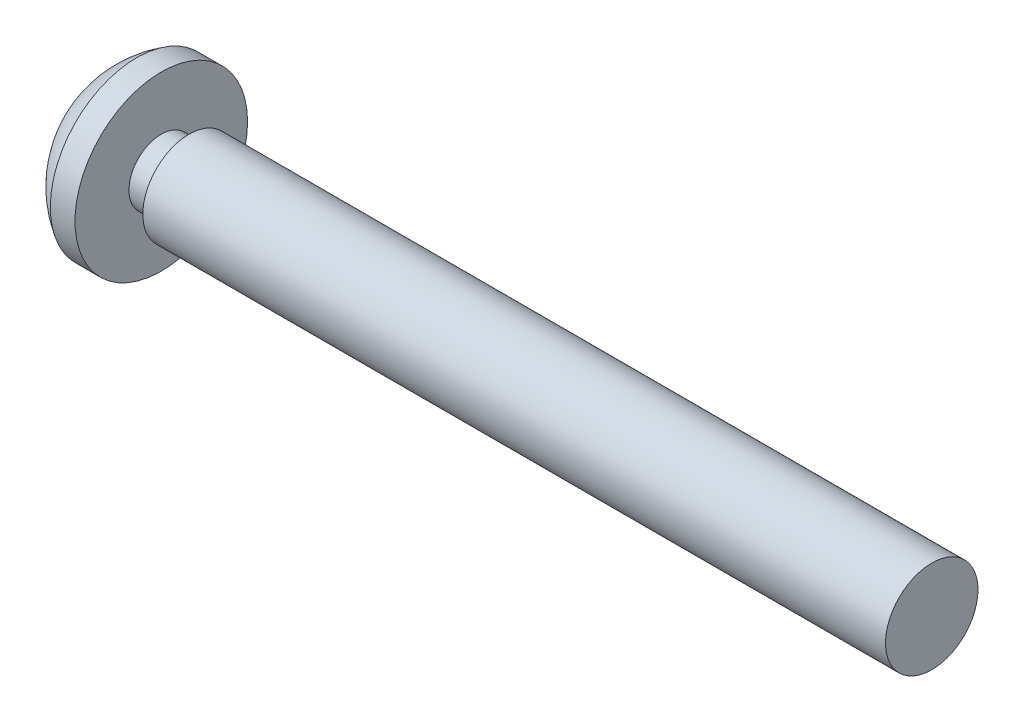
from build123d import *

# Parameters (mm, degrees)
CUT_EXTRUDE_5_DEPTH = 1.2


with BuildPart() as part:
    # 草图2 → 旋转1 (revolve)
    with BuildSketch(Plane.XY):
        with BuildLine():
            Line((0, 0), (0, 1.5))
            Line((0, 1.5), (-24.1, 1.5))
            Line((-24.1, 1.5), (-24.1, 1.05))
            Line((-24.1, 1.05), (-25, 1.05))
            Line((-25, 1.05), (-25, 2.8))
            Line((-25, 2.8), (-25.8, 2.8))
            ThreePointArc((-25.8, 2.8), (-26.971790212, 1.61245155), (-27.4, 0))
            Line((-27.4, 0), (0, 0))
        make_face()
    revolve(axis=Axis((0, 0, 0), (-1, 0, 0)))

    # 草图3 → 切除-拉伸5 (cut)
    with BuildSketch(Plane(origin=(-27.4, 0, 0), x_dir=(0, 0, -1), z_dir=(1, 0, 0))):
        with BuildLine():
            Line((0.375, 1.8), (-0.375, 1.8))
            Line((-0.375, 1.8), (-0.375, 0.675))
            ThreePointArc((-0.375, 0.675), (-0.462867966, 0.462867966), (-0.675, 0.375))
            Line((-0.675, 0.375), (-1.8, 0.375))
            Line((-1.8, 0.375), (-1.8, -0.375))
            Line((-1.8, -0.375), (-0.675, -0.375))
            ThreePointArc((-0.675, -0.375), (-0.462867966, -0.462867966), (-0.375, -0.675))
            Line((-0.375, -0.675), (-0.375, -1.8))
            Line((-0.375, -1.8), (0.375, -1.8))
            Line((0.375, -1.8), (0.375, -0.675))
            ThreePointArc((0.375, -0.675), (0.462867966, -0.462867966), (0.675, -0.375))
            Line((0.675, -0.375), (1.8, -0.375))
            Line((1.8, -0.375), (1.8, 0.375))
            Line((1.8, 0.375), (0.675, 0.375))
            ThreePointArc((0.675, 0.375), (0.462867966, 0.462867966), (0.375, 0.675))
            Line((0.375, 0.675), (0.375, 1.8))
        make_face()
    extrude(amount=CUT_EXTRUDE_5_DEPTH, mode=Mode.SUBTRACT)


solid = part.part
